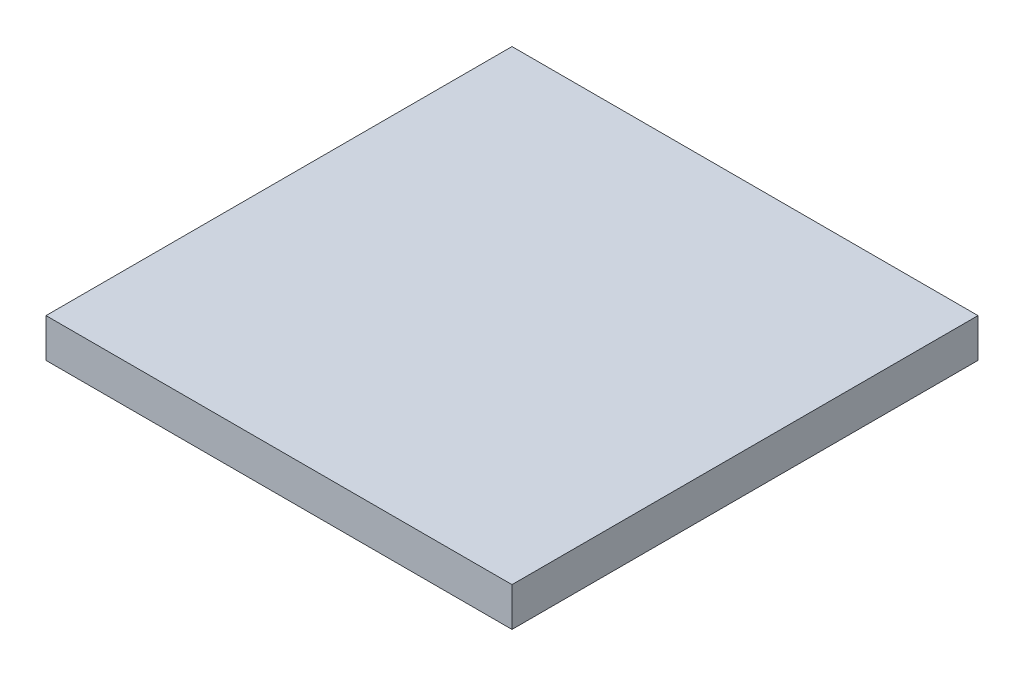
from build123d import *

# Parameters (mm, degrees)
BASES_W    = 1.2
BASES_H    = 1.2
BASE_DEPTH = 0.1


with BuildPart() as part:
    # BaseS → Base (new body)
    with BuildSketch(Plane(origin=(0, 0, 0), x_dir=(1, 0, 0), z_dir=(0, 1, 0))):
        Rectangle(BASES_W, BASES_H)
    extrude(amount=BASE_DEPTH)


solid = part.part
